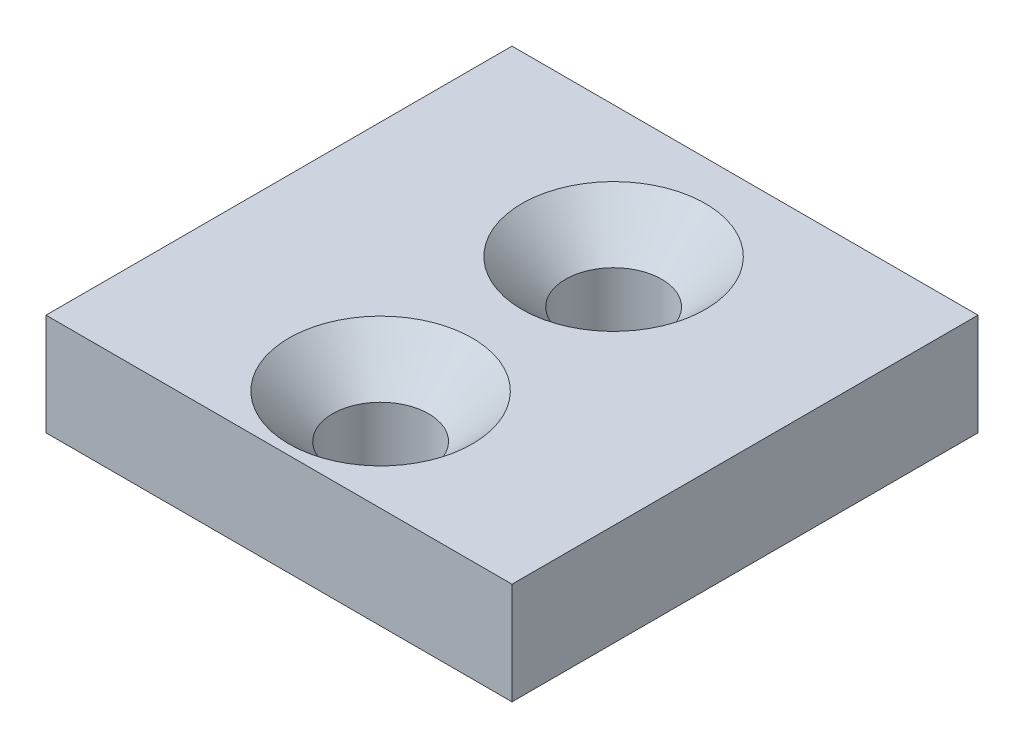
from build123d import *

# Parameters (mm, degrees)
IZIM1_W                     = 32
IZIM1_H                     = 32
Y_KSEKLIK_EKSTR_ZYON1_DEPTH = 7
DELIK2_D                    = 6.6
DELIK2_CSINK_D              = 12.6
DELIK2_CSINK_ANGLE          = 90


with BuildPart() as part:
    # Çizim1 → Yükseklik-Ekstrüzyon1 (new body)
    with BuildSketch(Plane(origin=(0, 0, 0), x_dir=(1, 0, 0), z_dir=(0, 1, 0))):
        with Locations((-16, 16)):
            Rectangle(IZIM1_W, IZIM1_H)
    extrude(amount=Y_KSEKLIK_EKSTR_ZYON1_DEPTH)

    # Delik2 (through all)
    with Locations(Plane(origin=(0, 7, 0), x_dir=(1, 0, 0), z_dir=(0, 1, 0))):
        with Locations((-16, 22.977076648), (-16, 6.977076648)):
            CounterSinkHole(DELIK2_D / 2, DELIK2_CSINK_D / 2, counter_sink_angle=DELIK2_CSINK_ANGLE)


solid = part.part
